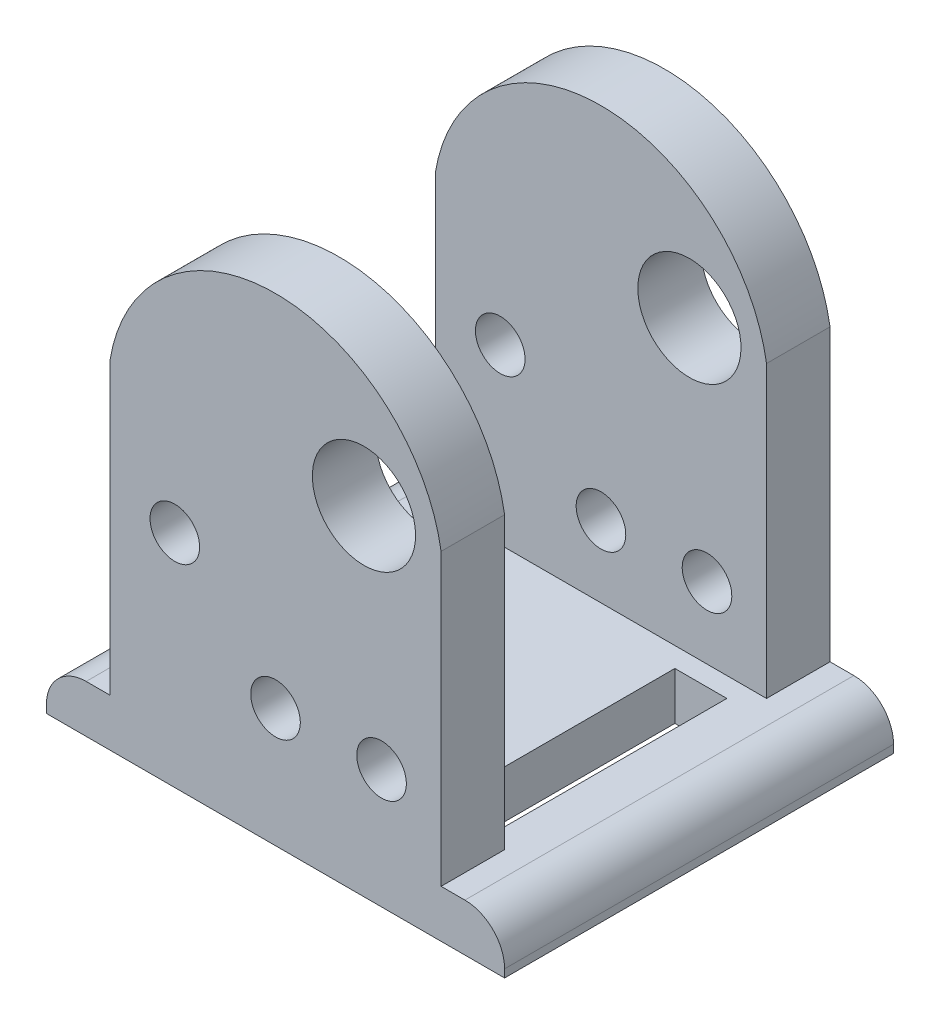
from build123d import *

# Parameters (mm, degrees)
SKETCH2_R           = 1.5875
SKETCH2_R_2         = 3.302
BOSS_EXTRUDE1_DEPTH = 24.892
CUT_EXTRUDE2_DEPTH  = 21.844
SKETCH4_W           = 3.326504507
SKETCH4_H           = 14.224
SKETCH4_W_2         = 3.81
CUT_EXTRUDE3_DEPTH  = 21.844
FILLET1_R           = 2.54


with BuildPart() as part:
    # Sketch2 → Boss-Extrude1 (new body)
    with BuildSketch(Plane.XY):
        with BuildLine():
            Line((8.660504507, -21.669967929), (-20.659495493, -21.669967929))
            Line((-20.659495493, -21.669967929), (-20.659495493, -18.621967929))
            Line((-20.659495493, -18.621967929), (-16.595495493, -18.621967929))
            Line((-16.595495493, -18.621967929), (-16.595495493, -0.055984768))
            ThreePointArc((-16.595495493, -0.055984768), (-5.999495493, 8.944015232), (4.596504507, -0.055984768))
            Line((4.596504507, -0.055984768), (4.596504507, -18.621967929))
            Line((4.596504507, -18.621967929), (8.660504507, -18.621967929))
            Line((8.660504507, -18.621967929), (8.660504507, -21.669967929))
        make_face()
        with Locations((-12.446, -7.546743134)):
            Circle(SKETCH2_R, mode=Mode.SUBTRACT)
        with Locations((-0.339495493, 0)):
            Circle(SKETCH2_R_2, mode=Mode.SUBTRACT)
        with Locations((-5.999495493, -14.049967929)):
            Circle(SKETCH2_R, mode=Mode.SUBTRACT)
        with Locations((0.786504507, -14.049967929)):
            Circle(SKETCH2_R, mode=Mode.SUBTRACT)
    extrude(amount=BOSS_EXTRUDE1_DEPTH)

    # Sketch3 → Cut-Extrude2 (cut)
    with BuildSketch(Plane.ZY.offset(16.595495493)):
        Polygon((20.828, -18.621967929), (20.828, 11.195500081), (4.064, 11.195500081), (4.064, -0.055984768), (4.064, -18.621967929), align=None)
    extrude(amount=-CUT_EXTRUDE2_DEPTH, mode=Mode.SUBTRACT)

    # Sketch4 → Cut-Extrude3 (cut)
    with BuildSketch(Plane(origin=(0, -18.621967929, 0), x_dir=(1, 0, 0), z_dir=(0, 1, 0))):
        with Locations((1.663252254, -12.446)):
            Rectangle(SKETCH4_W, SKETCH4_H)
        with Locations((-13.420495493, -12.446)):
            Rectangle(SKETCH4_W_2, SKETCH4_H)
    extrude(amount=-CUT_EXTRUDE3_DEPTH, mode=Mode.SUBTRACT)

    # Fillet1
    fillet1_edges = [part.edges().sort_by_distance(p)[0] for p in [
        (-20.659495493, -18.621967929, 12.446),
        (8.660504507, -18.621967929, 12.446),
    ]]
    fillet(fillet1_edges, radius=FILLET1_R)


solid = part.part
